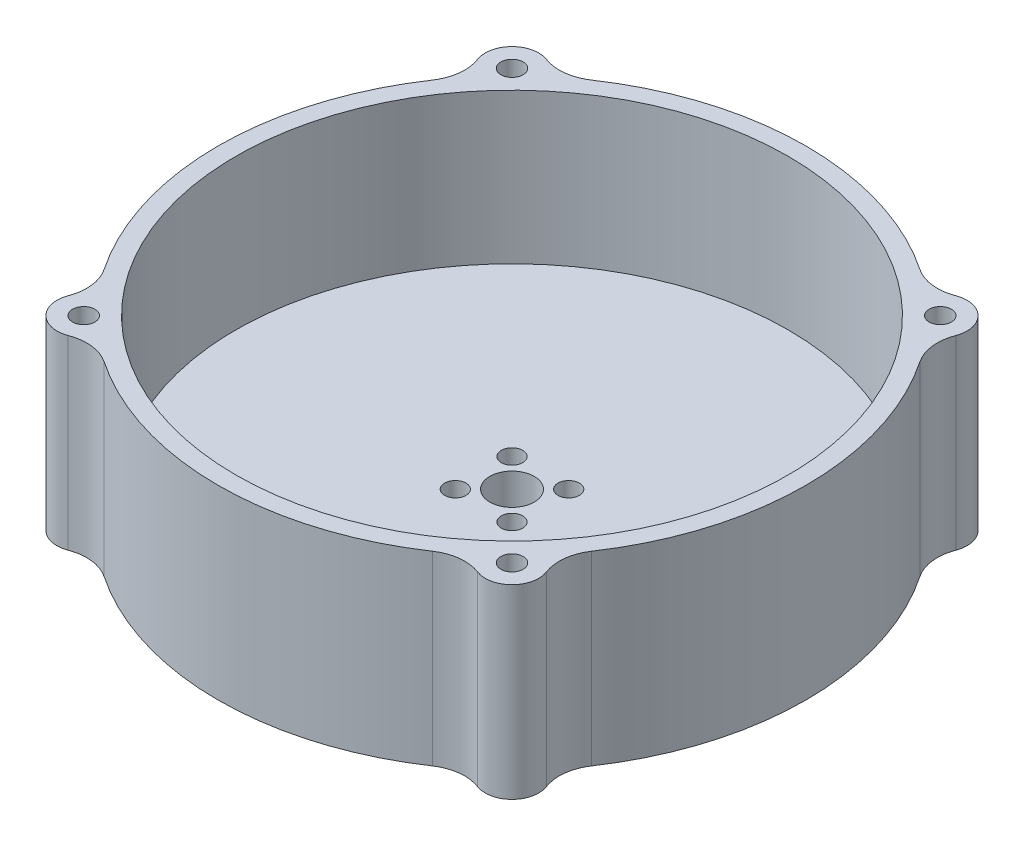
from build123d import *

# Parameters (mm, degrees)
SKETCH1_R                 = 33
BOSS_EXTRUDE1_DEPTH       = 4
SKETCH2_R                 = 33
SKETCH2_R_2               = 31
BOSS_EXTRUDE2_DEPTH       = 16.88
M2_CLEARANCE_HOLE1_D      = 2.4
SKETCH13_R                = 2.5
CUT_EXTRUDE3_DEPTH        = 5
CUT_EXTRUDE2_DEPTH        = 5
SKETCH15_R                = 3
BOSS_EXTRUDE3_DEPTH       = 20.88
FILLET1_R                 = 5
CIRPATTERN1_COUNT         = 4
FILLET1_OF_CIRPATTERN1_R  = 5
M3X0_5_TAPPED_HOLE1_D     = 2.5
M3X0_5_TAPPED_HOLE1_DEPTH = 7.5
M3X0_5_TAPPED_HOLE1_TIP   = 0.751075774


with BuildPart() as part:
    # Sketch1 → Boss-Extrude1 (new body)
    with BuildSketch(Plane(origin=(0, 0, 0), x_dir=(1, 0, 0), z_dir=(0, 1, 0))):
        Circle(SKETCH1_R)
    extrude(amount=BOSS_EXTRUDE1_DEPTH)

    # Sketch2 → Boss-Extrude2 (add)
    with BuildSketch(Plane(origin=(0, 4, 0), x_dir=(1, 0, 0), z_dir=(0, 1, 0))):
        Circle(SKETCH2_R)
        Circle(SKETCH2_R_2, mode=Mode.SUBTRACT)
    extrude(amount=BOSS_EXTRUDE2_DEPTH)

    # M2 Clearance Hole1 (through all)
    with Locations(Plane(origin=(0, 0, 0), x_dir=(-1, 0, 0), z_dir=(0, -1, 0))):
        with Locations((3.181980515, 3.181980515), (3.181980515, -3.181980515), (-3.181980515, -3.181980515), (-3.181980515, 3.181980515)):
            Hole(M2_CLEARANCE_HOLE1_D / 2)

    # Sketch13 → Cut-Extrude3 (cut, through all)
    with BuildSketch(Plane(origin=(0, 4, 0), x_dir=(1, 0, 0), z_dir=(0, 1, 0))):
        Circle(SKETCH13_R)
    extrude(amount=-CUT_EXTRUDE3_DEPTH, mode=Mode.SUBTRACT)

    # Sketch10 → Cut-Extrude2 (cut, through all)
    with BuildSketch(Plane(origin=(0, 4, 0), x_dir=(1, 0, 0), z_dir=(0, 1, 0))):
        with BuildLine():
            Line((13.5, -4), (13.5, 4))
            ThreePointArc((13.5, 4), (15, 5.5), (16.5, 4))
            Line((16.5, 4), (16.5, -4))
            ThreePointArc((16.5, -4), (15, -5.5), (13.5, -4))
        make_face()
    extrude(amount=-CUT_EXTRUDE2_DEPTH, mode=Mode.SUBTRACT)

    # Sketch15 → Boss-Extrude3 (add, through all)
    with BuildSketch(Plane(origin=(0, 20.88, 0), x_dir=(1, 0, 0), z_dir=(0, 1, 0))):
        with Locations((24.04163056, 24.04163056)):
            Circle(SKETCH15_R)
    boss_extrude3 = extrude(amount=-BOSS_EXTRUDE3_DEPTH)

    # Fillet1
    fillet1_edges = [part.edges().sort_by_distance(p)[0] for p in [
        (25.219946573, 10.44, -21.282722919),
        (21.282722919, 10.44, -25.219946573),
    ]]
    fillet(fillet1_edges, radius=FILLET1_R)

    # CirPattern1: Boss-Extrude3 ×4 about axis
    cirpattern1_axis = Axis((0, 0, 0), (0, 1, 0))
    for i in range(1, CIRPATTERN1_COUNT):
        add(boss_extrude3.rotate(cirpattern1_axis, i * 360 / CIRPATTERN1_COUNT))

    # Fillet1 of CirPattern1
    fillet1_of_cirpattern1_edges = [part.edges().sort_by_distance(p)[0] for p in [
        (-21.282722919, 10.44, -25.219946573),
        (-25.219946573, 10.44, -21.282722919),
        (-25.219946573, 10.44, 21.282722919),
        (-21.282722919, 10.44, 25.219946573),
        (21.282722919, 10.44, 25.219946573),
        (25.219946573, 10.44, 21.282722919),
    ]]
    fillet(fillet1_of_cirpattern1_edges, radius=FILLET1_OF_CIRPATTERN1_R)

    # M3x0.5 Tapped Hole1
    with Locations(Plane(origin=(0, 20.88, 0), x_dir=(1, 0, 0), z_dir=(0, 1, 0))):
        with Locations((24.04163056, -24.04163056), (-24.04163056, -24.04163056), (-24.04163056, 24.04163056), (24.04163056, 24.04163056)):
            Hole(M3X0_5_TAPPED_HOLE1_D / 2, depth=M3X0_5_TAPPED_HOLE1_DEPTH)
            with Locations((0, 0, -(M3X0_5_TAPPED_HOLE1_DEPTH + M3X0_5_TAPPED_HOLE1_TIP / 2))):  # 118° drill point
                Cone(0, M3X0_5_TAPPED_HOLE1_D / 2, M3X0_5_TAPPED_HOLE1_TIP, mode=Mode.SUBTRACT)


solid = part.part
